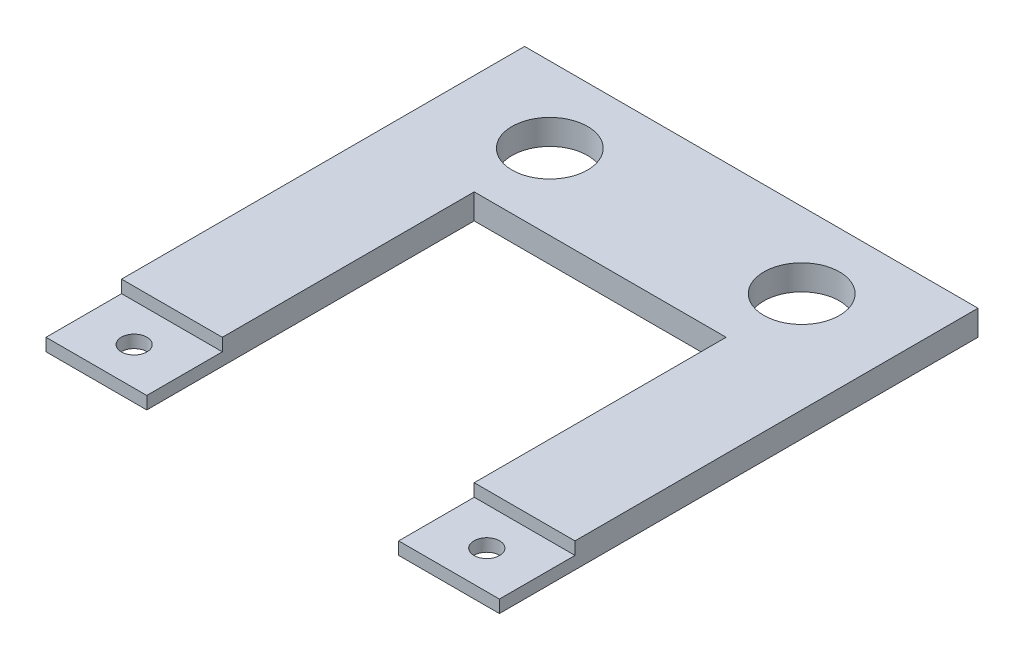
from build123d import *

# Parameters (mm, degrees)
BOSS_EXTRUDE1_DEPTH = 0.79375
SKETCH2_W           = 6.35
SKETCH2_H           = 4.7625
CUT_EXTRUDE1_DEPTH  = 0.79375
SKETCH3_R           = 0.80645
SKETCH3_R_2         = 2.38125
CUT_EXTRUDE2_DEPTH  = 1.5875


with BuildPart() as part:
    # Sketch1 → Boss-Extrude1 (new body, symmetric)
    with BuildSketch(Plane(origin=(0, 0, 0), x_dir=(1, 0, 0), z_dir=(0, 1, 0))):
        Polygon((14.2875, 15.08125), (-14.2875, 15.08125), (-14.2875, -15.08125), (-7.9375, -15.08125), (-7.9375, 5.55625), (7.9375, 5.55625), (7.9375, -15.08125), (14.2875, -15.08125), align=None)
    extrude(amount=BOSS_EXTRUDE1_DEPTH, both=True)

    # Sketch2 → Cut-Extrude1 (cut)
    with BuildSketch(Plane(origin=(0, 0.79375, 0), x_dir=(1, 0, 0), z_dir=(0, 1, 0))):
        with Locations((-11.1125, -12.7)):
            Rectangle(SKETCH2_W, SKETCH2_H)
        with Locations((11.1125, -12.7)):
            Rectangle(SKETCH2_W, SKETCH2_H)
    extrude(amount=-CUT_EXTRUDE1_DEPTH, mode=Mode.SUBTRACT)

    # Sketch3 → Cut-Extrude2 (cut)
    with BuildSketch(Plane(origin=(0, 0.79375, 0), x_dir=(1, 0, 0), z_dir=(0, 1, 0))):
        with Locations((-11.1125, -12.7)):
            Circle(SKETCH3_R)
        with Locations((-7.9375, 10.31875)):
            Circle(SKETCH3_R_2)
        with Locations((11.1125, -12.7)):
            Circle(SKETCH3_R)
        with Locations((7.9375, 10.31875)):
            Circle(SKETCH3_R_2)
    extrude(amount=-CUT_EXTRUDE2_DEPTH, mode=Mode.SUBTRACT)


solid = part.part
